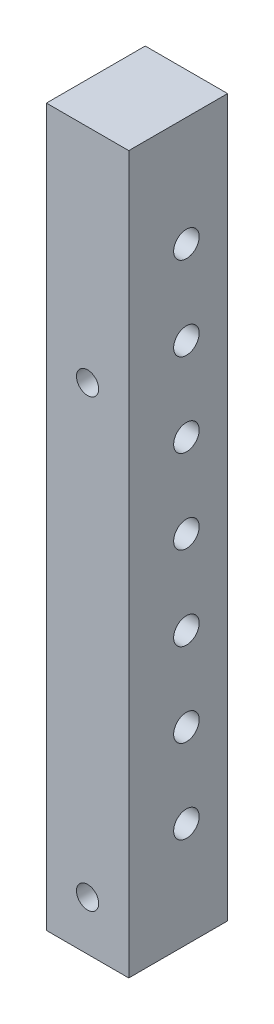
from build123d import *

# Parameters (mm, degrees)
SKETCH_1_W                  = 12
SKETCH_1_H                  = 87
EXTRUDE_1_DEPTH             = 10
HOLE_WIZARD_3_1_3_1_1_D     = 3.1
HOLE_WIZARD_3_1_3_1_1_DEPTH = 10
HOLE_WIZARD_2_7_2_7_1_D     = 2.7
HOLE_WIZARD_2_7_2_7_1_DEPTH = 12


with BuildPart() as part:
    # 草圖1 → 填料-伸長1 (new body)
    with BuildSketch(Plane(origin=(5, 0, 0), x_dir=(0, 0, -1), z_dir=(1, 0, 0))):
        with Locations((0, 43.5)):
            Rectangle(SKETCH_1_W, SKETCH_1_H)
    extrude(amount=-EXTRUDE_1_DEPTH)

    # Ø3.1 (3.1) 直徑孔1
    with Locations(Plane(origin=(5, 0, 0), x_dir=(0, 0, -1), z_dir=(1, 0, 0))):
        with Locations((1, 63.53), (1, 43.21), (1, 22.89), (1, 53.37), (1, 33.05), (1, 12.73), (1, 73.69)):
            Hole(HOLE_WIZARD_3_1_3_1_1_D / 2, depth=HOLE_WIZARD_3_1_3_1_1_DEPTH)

    # Ø2.7 (2.7) 直徑孔1
    with Locations(Plane.XY.offset(6)):
        with Locations((0, 60.1), (0, 6)):
            Hole(HOLE_WIZARD_2_7_2_7_1_D / 2, depth=HOLE_WIZARD_2_7_2_7_1_DEPTH)


solid = part.part
